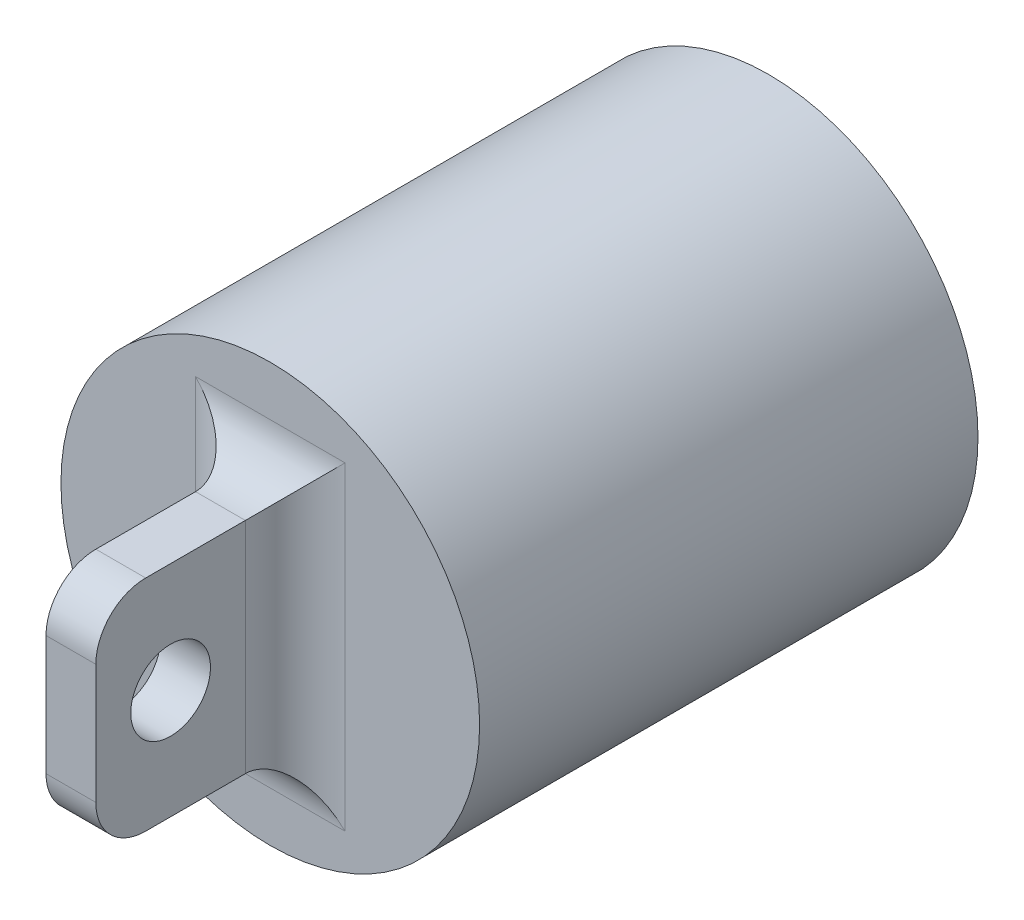
from build123d import *

# Parameters (mm, degrees)
SKETCH1_R           = 21
BOSS_EXTRUDE1_DEPTH = 50
SKETCH2_W           = 20
SKETCH2_H           = 22
BOSS_EXTRUDE2_DEPTH = 2.5
FILLET1_R           = 5
FILLET2_R           = 5
SKETCH3_R           = 4
CUT_EXTRUDE1_DEPTH  = 24.5


with BuildPart() as part:
    # Sketch1 → Boss-Extrude1 (new body)
    with BuildSketch(Plane.XY):
        Circle(SKETCH1_R)
    extrude(amount=BOSS_EXTRUDE1_DEPTH)

    # Sketch2 → Boss-Extrude2 (add, symmetric)
    with BuildSketch(Plane(origin=(0, 0, 0), x_dir=(0, 0, -1), z_dir=(1, 0, 0))):
        with Locations((-60, 0)):
            Rectangle(SKETCH2_W, SKETCH2_H)
    extrude(amount=BOSS_EXTRUDE2_DEPTH, both=True)

    # Fillet1
    fillet1_edges = [part.edges().sort_by_distance(p)[0] for p in [
        (-2.5, 0, 50),
        (0, -11, 50),
        (0, 11, 50),
        (2.5, 0, 50),
    ]]
    fillet(fillet1_edges, radius=FILLET1_R)

    # Fillet2
    fillet2_edges = [part.edges().sort_by_distance(p)[0] for p in [
        (0, 11, 70),
        (0, -11, 70),
    ]]
    fillet(fillet2_edges, radius=FILLET2_R)

    # Sketch3 → Cut-Extrude1 (cut, through all)
    with BuildSketch(Plane(origin=(2.5, 0, 0), x_dir=(0, 0, -1), z_dir=(1, 0, 0))):
        with Locations((-62.5, 0)):
            Circle(SKETCH3_R)
    extrude(amount=-CUT_EXTRUDE1_DEPTH, mode=Mode.SUBTRACT)


solid = part.part
